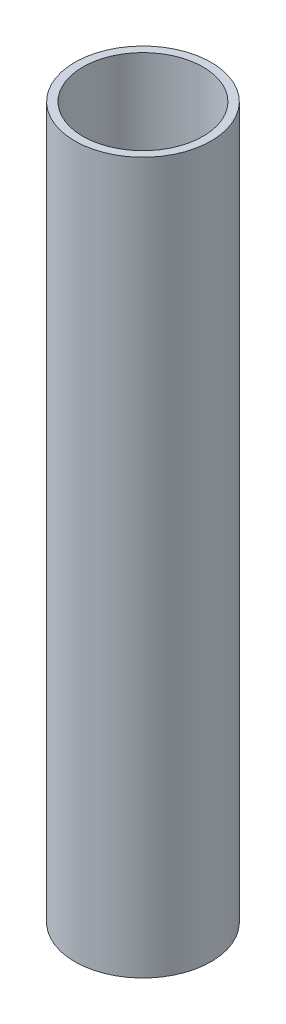
from build123d import *

# Parameters (mm, degrees)
SKETCH1_R           = 28.575
SKETCH1_R_2         = 25.2
BOSS_EXTRUDE1_DEPTH = 149


with BuildPart() as part:
    # Sketch1 → Boss-Extrude1 (new body, symmetric)
    with BuildSketch(Plane(origin=(0, 0, 0), x_dir=(1, 0, 0), z_dir=(0, 1, 0))):
        Circle(SKETCH1_R)
        Circle(SKETCH1_R_2, mode=Mode.SUBTRACT)
    extrude(amount=BOSS_EXTRUDE1_DEPTH, both=True)


solid = part.part
